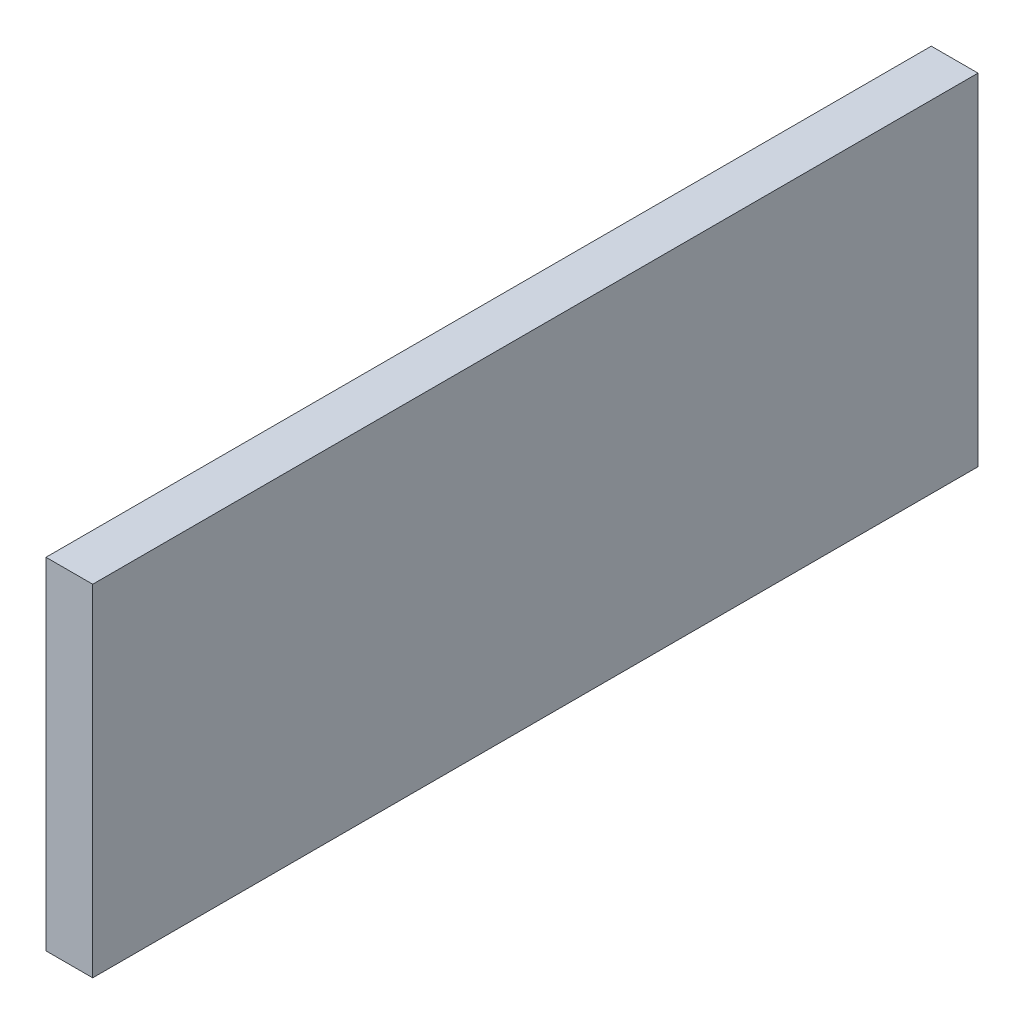
from build123d import *

# Parameters (mm, degrees)
SKETCH1_W           = 3.175
SKETCH1_H           = 23.17
BOSS_EXTRUDE1_DEPTH = 60.17


with BuildPart() as part:
    # Sketch1 → Boss-Extrude1 (new body)
    with BuildSketch(Plane.XY):
        Rectangle(SKETCH1_W, SKETCH1_H)
    extrude(amount=BOSS_EXTRUDE1_DEPTH)


solid = part.part
